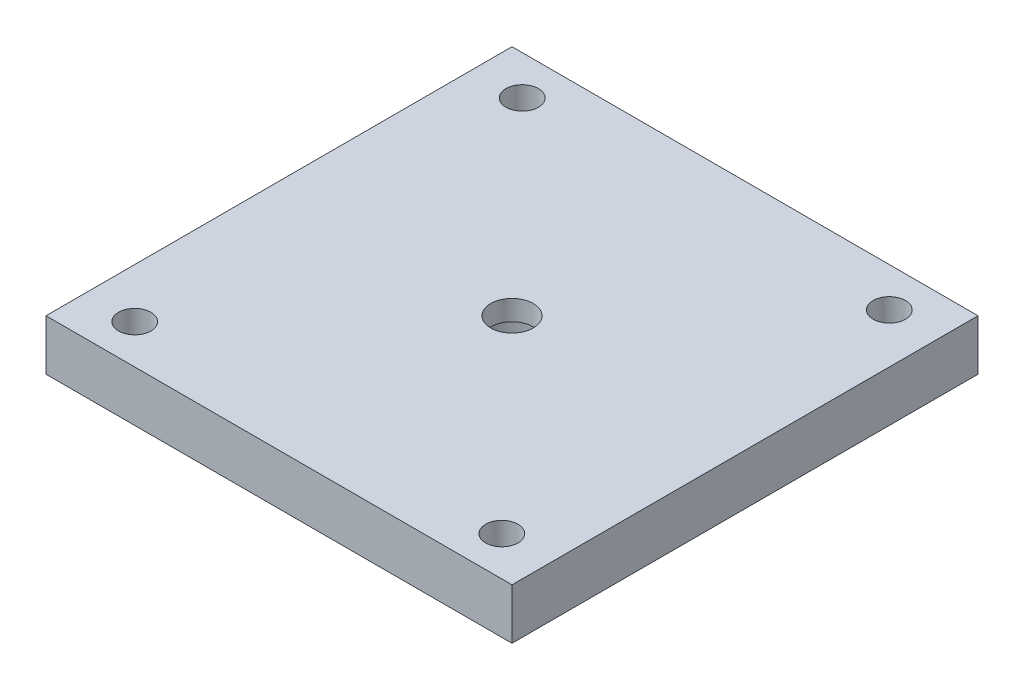
from build123d import *

# Parameters (mm, degrees)
SKETCH1_W           = 46
SKETCH1_H           = 46
BOSS_EXTRUDE1_DEPTH = 5
SKETCH3_R           = 4.1
CUT_EXTRUDE2_DEPTH  = 3
SKETCH4_R           = 2.1
CUT_EXTRUDE3_DEPTH  = 6
SKETCH5_W           = 5
SKETCH5_H           = 5
BOSS_EXTRUDE2_DEPTH = 2
SKETCH6_R           = 1
CUT_EXTRUDE4_DEPTH  = 5
SKETCH7_R           = 1.6
CUT_EXTRUDE5_DEPTH  = 5


with BuildPart() as part:
    # Sketch1 → Boss-Extrude1 (new body)
    with BuildSketch(Plane(origin=(0, 0, 0), x_dir=(1, 0, 0), z_dir=(0, 1, 0))):
        Rectangle(SKETCH1_W, SKETCH1_H)
    extrude(amount=BOSS_EXTRUDE1_DEPTH)

    # Sketch3 → Cut-Extrude2 (cut)
    with BuildSketch(Plane(origin=(0, 0, 0), x_dir=(1, 0, 0), z_dir=(0, 1, 0))):
        Circle(SKETCH3_R)
    extrude(amount=CUT_EXTRUDE2_DEPTH, mode=Mode.SUBTRACT)

    # Sketch4 → Cut-Extrude3 (cut, through all)
    with BuildSketch(Plane(origin=(0, 0, 0), x_dir=(1, 0, 0), z_dir=(0, 1, 0))):
        Circle(SKETCH4_R)
    extrude(amount=CUT_EXTRUDE3_DEPTH, mode=Mode.SUBTRACT)

    # Sketch5 → Boss-Extrude2 (add)
    with BuildSketch(Plane(origin=(0, 0, 0), x_dir=(1, 0, 0), z_dir=(0, 1, 0))):
        with Locations((7.5, 0)):
            Rectangle(SKETCH5_W, SKETCH5_H)
        with Locations((-7.5, 0)):
            Rectangle(SKETCH5_W, SKETCH5_H)
    extrude(amount=-BOSS_EXTRUDE2_DEPTH)

    # Sketch6 → Cut-Extrude4 (cut)
    with BuildSketch(Plane(origin=(0, -2, 0), x_dir=(-1, 0, 0), z_dir=(0, -1, 0))):
        with Locations((7.5, 0)):
            Circle(SKETCH6_R)
        with Locations((-7.5, 0)):
            Circle(SKETCH6_R)
    extrude(amount=-CUT_EXTRUDE4_DEPTH, mode=Mode.SUBTRACT)

    # Sketch7 → Cut-Extrude5 (cut)
    with BuildSketch(Plane(origin=(0, 0, 0), x_dir=(1, 0, 0), z_dir=(0, 1, 0))):
        with Locations((-18.12, -19.125)):
            Circle(SKETCH7_R)
        with Locations((18.12, -19.125)):
            Circle(SKETCH7_R)
        with Locations((18.12, 19.125)):
            Circle(SKETCH7_R)
        with Locations((-18.12, 19.125)):
            Circle(SKETCH7_R)
    extrude(amount=CUT_EXTRUDE5_DEPTH, mode=Mode.SUBTRACT)


solid = part.part
